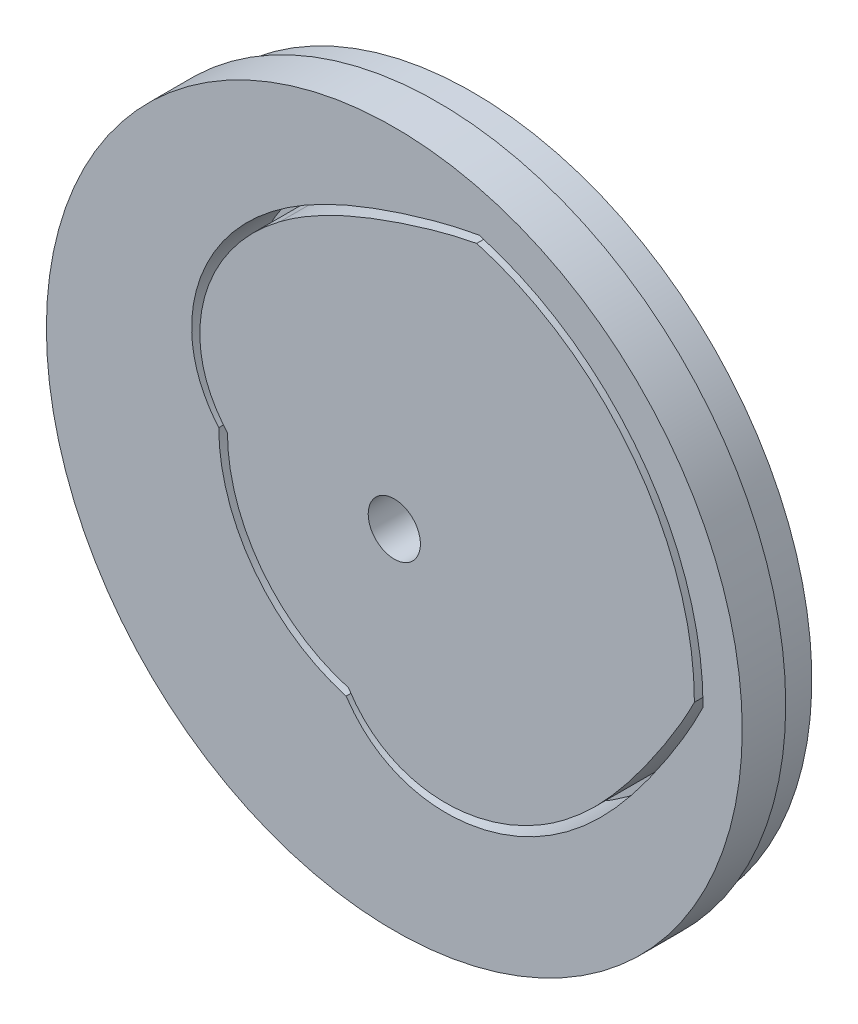
from build123d import *

# Parameters (mm, degrees)
SKETCH_1_R          = 36
EXTRUDE_1_DEPTH     = 2
SKETCH_2_R          = 30
EXTRUDE_2_DEPTH     = 5
SKETCH_3_R          = 3
CUT_EXTRUDE_1_DEPTH = 25
SKETCH_4_R          = 39
EXTRUDE_3_DEPTH     = 2
SKETCH_5_R          = 40
EXTRUDE_4_DEPTH     = 5
SKETCH_6_R          = 3
CUT_EXTRUDE_2_DEPTH = 10
SKETCH_7_R          = 39
EXTRUDE_5_DEPTH     = 2
CUT_EXTRUDE_3_DEPTH = 8
SKETCH_11_R         = 3
CUT_EXTRUDE_4_DEPTH = 10


with BuildPart() as part:
    # 草图1 → 凸台-拉伸1 (new body)
    with BuildSketch(Plane.XY):
        Circle(SKETCH_1_R)
    extrude(amount=EXTRUDE_1_DEPTH)

    # 草图2 → 凸台-拉伸2 (add)
    with BuildSketch(Plane.XY.offset(2)):
        Circle(SKETCH_2_R)
    extrude(amount=EXTRUDE_2_DEPTH)

    # 草图3 → 切除-拉伸1 (cut)
    with BuildSketch(Plane(origin=(0, 0, 0), x_dir=(-1, 0, 0), z_dir=(0, 0, -1))):
        Circle(SKETCH_3_R)
    extrude(amount=-CUT_EXTRUDE_1_DEPTH, mode=Mode.SUBTRACT)

    # 草图4 → 凸台-拉伸3 (add)
    with BuildSketch(Plane(origin=(0, 0, 0), x_dir=(-1, 0, 0), z_dir=(0, 0, -1))):
        Circle(SKETCH_4_R)
    extrude(amount=-EXTRUDE_3_DEPTH)

    # 草图5 → 凸台-拉伸4 (add)
    with BuildSketch(Plane.XY.offset(7)):
        Circle(SKETCH_5_R)
    extrude(amount=-EXTRUDE_4_DEPTH)

    # 草图6 → 切除-拉伸2 (cut)
    with BuildSketch(Plane(origin=(0, 0, 0), x_dir=(-1, 0, 0), z_dir=(0, 0, -1))):
        Circle(SKETCH_6_R)
    extrude(amount=-CUT_EXTRUDE_2_DEPTH, mode=Mode.SUBTRACT)

    # 草图7 → 凸台-拉伸5 (add)
    with BuildSketch(Plane(origin=(0, 0, 0), x_dir=(-1, 0, 0), z_dir=(0, 0, -1))):
        Circle(SKETCH_7_R)
    extrude(amount=EXTRUDE_5_DEPTH)

    # 草图9 → 切除-拉伸3 (cut, through all)
    with BuildSketch(Plane.XY):
        with BuildLine():
            ThreePointArc((9.750517331, 34.134695132), (28.340724808, 21.378805331), (35.5, 0))
            add(Edge.make_bspline(
                [(35.5, 0), (35.291831716, -0.433383755), (34.96980107, -1.074592529), (34.52418154, -1.915308269), (34.187218858, -2.531250794), (33.846850563, -3.136125059), (33.503977838, -3.730227641), (33.159288353, -4.31386212), (32.813411624, -4.887391808), (32.466780261, -5.45117135), (32.005816301, -6.186619882), (31.544345288, -6.90909253), (31.076364296, -7.615922545), (30.729539293, -8.135423458), (30.381597048, -8.647502186), (30.033478459, -9.152056858), (29.570761971, -9.811988074), (29.104673867, -10.460815875), (28.634649226, -11.098388551), (28.282371873, -11.567841648), (27.92861643, -12.030677745), (27.573187362, -12.487003446), (27.215827327, -12.936851733), (26.856351511, -13.380290873), (26.494533103, -13.81733315), (26.010016529, -14.38997063), (25.518692174, -14.9515568), (25.019993436, -15.501415577), (24.643682888, -15.90626894), (24.263999584, -16.304545875), (23.880813008, -16.696175021), (23.366072554, -17.208377634), (22.713223292, -17.831826042), (22.045042308, -18.434016116), (21.502579759, -18.901037327), (21.09236886, -19.243323179), (20.678094987, -19.578075579), (20.259732543, -19.905143208), (19.837292779, -20.22440024), (19.410768219, -20.535676054), (18.980204542, -20.838859753), (18.545542144, -21.133651278), (18.107023875, -21.420198703), (17.517720614, -21.790150941), (16.62329103, -22.318325608), (15.7067858, -22.80295008), (14.623171032, -23.322232407), (13.837904271, -23.660560667), (13.041508576, -23.964526743), (12.561991359, -24.135860585), (12.079951879, -24.296349082), (11.595562292, -24.445767316), (11.10901483, -24.583905748), (10.458457055, -24.752534599), (9.803605775, -24.898001802), (9.145603452, -25.019145994), (8.651622009, -25.097480876), (8.156913973, -25.163146926), (7.661759162, -25.215898805), (7.166458386, -25.255485986), (6.671327047, -25.281650862), (6.17669929, -25.294143558), (5.682922868, -25.292727141), (5.190368209, -25.2770878), (4.699415784, -25.247017461), (4.210489856, -25.202244466), (3.723954401, -25.142467722), (2.439986898, -24.943551988), (1.175279325, -24.597845247), (-0.021822821, -24.097714557), (-0.463649413, -23.893489908), (-0.897552628, -23.672528344), (-1.322955162, -23.434869075), (-1.739200354, -23.180599491), (-2.145616319, -22.909839492), (-2.541596739, -22.622881923), (-2.926463418, -22.320009878), (-3.299660517, -22.001730531), (-3.660561801, -21.66856071), (-4.008686645, -21.321253094), (-4.343545551, -20.960637151), (-4.664752517, -20.587727939), (-5.074146394, -20.076174898), (-5.360533295, -19.676978176), (-5.543215795, -19.405737645)],
                knots=[0, 0, 0, 0, 0.026563969, 0.039640384, 0.05257194, 0.065355143, 0.077988297, 0.090471413, 0.102805833, 0.114993314, 0.127037876, 0.150763336, 0.162357092, 0.173875575, 0.185275851, 0.196563707, 0.207744758, 0.229808392, 0.240701862, 0.251509872, 0.262237274, 0.272888592, 0.283468254, 0.293980283, 0.304428565, 0.314816728, 0.335425387, 0.345652335, 0.355831222, 0.365964562, 0.376054677, 0.386103708, 0.406085782, 0.425925221, 0.435795506, 0.445634417, 0.45544314, 0.465222771, 0.474974271, 0.484698547, 0.494396408, 0.50406868, 0.513715654, 0.523338337, 0.542511584, 0.571097127, 0.580582239, 0.608903234, 0.618301964, 0.627679451, 0.637035769, 0.64637102, 0.655685281, 0.664978638, 0.683501515, 0.692732564, 0.701943084, 0.711133234, 0.720303225, 0.729453327, 0.738583878, 0.747695263, 0.756787959, 0.765862682, 0.774920056, 0.78396098, 0.792986518, 0.801997762, 0.855760925, 0.864720518, 0.873681538, 0.882646657, 0.891618236, 0.90059859, 0.909589965, 0.918593788, 0.9276114, 0.936642769, 0.945687449, 0.954743092, 0.963806242, 0.972871393, 0.981930868, 1, 1, 1, 1], degree=3))
            ThreePointArc((-5.543215795, -19.405737645), (-16.111837769, -12.153953208), (-20.18192, 0))
            add(Edge.make_bspline(
                [(9.750517331, 34.134695132), (9.276625195, 34.053567102), (8.571627127, 33.920037506), (7.640849763, 33.72246924), (6.956044952, 33.567642194), (6.28094733, 33.406500476), (5.615519246, 33.23999207), (4.959657675, 33.068861581), (4.313186179, 32.893814101), (3.675882576, 32.715363011), (2.84210938, 32.474127501), (2.020673754, 32.228840452), (1.21249111, 31.972997348), (0.617710027, 31.782198387), (0.02975881, 31.588286558), (-0.551006154, 31.392138591), (-1.312647731, 31.128476182), (-2.064538979, 30.858522137), (-2.806689187, 30.58169159), (-3.354844814, 30.371903718), (-3.897043903, 30.15887716), (-4.433442662, 29.942453181), (-4.964143489, 29.722393397), (-5.489262786, 29.498538852), (-6.00887466, 29.27067483), (-6.692567422, 28.96207444), (-7.367503742, 28.643892711), (-8.033189161, 28.315399137), (-8.525830532, 28.064759248), (-9.013074768, 27.809070018), (-9.494889102, 27.54818635), (-10.128772645, 27.193925279), (-10.907556852, 26.737422011), (-11.670111355, 26.260337802), (-12.268165359, 25.867011173), (-12.709956674, 25.566589769), (-13.145620215, 25.260192494), (-13.575017513, 24.947753173), (-13.99802449, 24.629248065), (-14.414479141, 24.304623119), (-14.824262289, 23.973891796), (-15.227101784, 23.636914371), (-15.623073304, 23.293965025), (-16.140656924, 22.828937943), (-16.894184597, 22.113977241), (-17.611900337, 21.365828302), (-18.408839731, 20.466515952), (-18.949839426, 19.804376068), (-19.460855182, 19.122097258), (-19.757305025, 18.708080908), (-20.044019397, 18.28866049), (-20.320734747, 17.863939763), (-20.587196796, 17.434046014), (-20.928024099, 16.854824245), (-21.2477598, 16.265112462), (-21.544973409, 15.665690204), (-21.755973745, 15.21222259), (-21.954992052, 14.754576673), (-22.141715569, 14.292954126), (-22.315820785, 13.82757538), (-22.47697337, 13.358672951), (-22.624841283, 12.886499502), (-22.759101186, 12.411324335), (-22.879349598, 11.933417439), (-22.985281943, 11.453087504), (-23.076520484, 10.97066786), (-23.152675736, 10.486425786), (-23.314067834, 9.19720408), (-23.329024422, 7.886183601), (-23.176927425, 6.597754031), (-23.10191029, 6.116826932), (-23.008623676, 5.638921481), (-22.896946721, 5.164603548), (-22.766783093, 4.694528542), (-22.618063541, 4.229375439), (-22.450903113, 3.769807673), (-22.265387741, 3.316555114), (-22.061852425, 2.870291523), (-21.840622115, 2.431761004), (-21.60228853, 2.001632431), (-21.347514791, 1.580604299), (-21.0771709, 1.169326564), (-20.697736955, 0.635173269), (-20.392552787, 0.250156252), (-20.18192, 0)],
                knots=[0, 0, 0, 0, 0.026563969, 0.039640384, 0.05257194, 0.065355143, 0.077988297, 0.090471413, 0.102805833, 0.114993314, 0.127037876, 0.150763336, 0.162357092, 0.173875575, 0.185275851, 0.196563707, 0.207744758, 0.229808392, 0.240701862, 0.251509872, 0.262237274, 0.272888592, 0.283468254, 0.293980283, 0.304428565, 0.314816728, 0.335425387, 0.345652335, 0.355831222, 0.365964562, 0.376054677, 0.386103708, 0.406085782, 0.425925221, 0.435795506, 0.445634417, 0.45544314, 0.465222771, 0.474974271, 0.484698547, 0.494396408, 0.50406868, 0.513715654, 0.523338337, 0.542511584, 0.571097127, 0.580582239, 0.608903234, 0.618301964, 0.627679451, 0.637035769, 0.64637102, 0.655685281, 0.664978638, 0.683501515, 0.692732564, 0.701943084, 0.711133234, 0.720303225, 0.729453327, 0.738583878, 0.747695263, 0.756787959, 0.765862682, 0.774920056, 0.78396098, 0.792986518, 0.801997762, 0.855760925, 0.864720518, 0.873681538, 0.882646657, 0.891618236, 0.90059859, 0.909589965, 0.918593788, 0.9276114, 0.936642769, 0.945687449, 0.954743092, 0.963806242, 0.972871393, 0.981930868, 1, 1, 1, 1], degree=3))
        make_face()
        with BuildLine():
            ThreePointArc((34.500125587, 2.0246e-05), (27.542495364, 20.776660334), (9.475910662, 33.173269098))
            add(Edge.make_bspline(
                [(9.475910662, 33.173269098), (9.013913327, 33.088680351), (8.326808416, 32.950488792), (7.420043536, 32.747192756), (6.75331292, 32.588451315), (6.096358822, 32.423726512), (5.449135609, 32.253973709), (4.811539365, 32.07992431), (4.183369793, 31.902335747), (3.564459688, 31.72153339), (2.954440076, 31.53828841), (2.352525087, 31.351665668), (1.758990071, 31.165688291), (0.984309831, 30.911189088), (0.220337484, 30.655169), (-0.533246889, 30.392264086), (-1.270235467, 30.12935389), (-2.175420837, 29.794996076), (-3.067464519, 29.449341561), (-3.768708175, 29.167116193), (-4.286792713, 28.953230031), (-4.799229233, 28.736045918), (-5.473007881, 28.442776413), (-6.302109339, 28.066899275), (-7.11816844, 27.675355256), (-7.760089554, 27.353350014), (-8.547980485, 26.946168197), (-9.322302527, 26.521335434), (-10.081266264, 26.077572125), (-10.529258211, 25.807158533), (-10.971694032, 25.531414666), (-11.408457906, 25.250196969), (-11.839478469, 24.963462846), (-12.405461461, 24.574285655), (-12.822346782, 24.272983826), (-13.096470327, 24.067932955)],
                knots=[0, 0, 0, 0, 0.057468943, 0.085747572, 0.113703692, 0.141329188, 0.168619993, 0.195575901, 0.222199665, 0.248495134, 0.274471054, 0.300136345, 0.325604897, 0.350577138, 0.399909964, 0.424192528, 0.448235956, 0.495654563, 0.542261904, 0.565289675, 0.588147159, 0.610844297, 0.633390119, 0.678061544, 0.722224403, 0.7441329, 0.765934053, 0.830744152, 0.852168247, 0.873509251, 0.89477083, 0.915956589, 0.937069567, 0.958112714, 1, 1, 1, 1], degree=3))
            add(Edge.make_bspline(
                [(-13.096470327, 24.067932955), (-13.368963871, 23.864120075), (-13.77213365, 23.552158671), (-14.298173799, 23.1233423), (-14.685376955, 22.796234792), (-15.065898088, 22.463442741), (-15.439312594, 22.124672191), (-15.805582669, 21.780081052), (-16.164491187, 21.429648803), (-16.515860693, 21.073411924), (-16.859497479, 20.711403416), (-17.195198153, 20.343663263), (-17.522778751, 19.970261176), (-17.842001633, 19.59123373), (-18.15266064, 19.206659576), (-18.454537459, 18.816621075), (-18.747404901, 18.421205896), (-19.031014722, 18.020501892), (-19.305142161, 17.614621735), (-19.5695186, 17.203680977), (-19.82391187, 16.78776272), (-20.550400382, 15.5357346), (-21.160006232, 14.214541123), (-21.617168003, 12.847751758), (-21.755744211, 12.391540553), (-21.880999444, 11.932518869), (-21.99254555, 11.470921631), (-22.090079076, 11.007066815), (-22.17322017, 10.541250718), (-22.241603605, 10.073845838), (-22.294848845, 9.605063313), (-22.445544604, 7.740069827), (-22.239355508, 5.817714268), (-21.634875161, 4.04547041), (-21.464499432, 3.604036513), (-21.276078194, 3.169065137), (-21.069982947, 2.741109475), (-20.846531739, 2.320938845), (-20.606318622, 1.909206667), (-20.350007882, 1.506607746), (-20.078470939, 1.113784619), (-19.697869025, 0.60419586), (-19.392437234, 0.237795434), (-19.181864208, 0.000114673)],
                knots=[0, 0, 0, 0, 0.036454691, 0.054604205, 0.072704004, 0.090754654, 0.108758162, 0.126715261, 0.144626885, 0.162493865, 0.180316934, 0.198096729, 0.215833755, 0.233528582, 0.251181595, 0.268793115, 0.286363443, 0.303892874, 0.321381592, 0.338829843, 0.356237829, 0.373605776, 0.493926776, 0.510985841, 0.528009093, 0.54499761, 0.561952954, 0.578876512, 0.595770236, 0.612636413, 0.6294774, 0.646296276, 0.813191496, 0.830049983, 0.846939631, 0.86386334, 0.880821258, 0.897812697, 0.914833155, 0.931875915, 0.948930156, 0.965980721, 1, 1, 1, 1], degree=3))
            ThreePointArc((-19.181864208, 0.000114673), (-15.313463272, -11.551699319), (-5.268428766, -18.444174497))
            add(Edge.make_bspline(
                [(19.545187475, -19.203348101), (19.274369336, -19.409381974), (18.863670127, -19.71136202), (18.306862227, -20.099391247), (17.885984855, -20.381858668), (17.461476865, -20.656339721), (17.033172229, -20.922345393), (16.601233168, -21.179882706), (16.165699585, -21.428737249), (15.726655297, -21.668748411), (15.284185243, -21.899738998), (14.838383731, -22.121524422), (14.389368319, -22.333946942), (13.937239447, -22.536788102), (13.482129365, -22.729871275), (13.024177229, -22.913009166), (12.563529736, -23.086007402), (12.100339544, -23.248651417), (11.634776725, -23.40075604), (11.167026167, -23.542094723), (10.697231543, -23.672467051), (9.293816397, -24.027130129), (7.85599923, -24.250408639), (6.416210438, -24.314582483), (5.93948311, -24.32252503), (5.463712164, -24.316886984), (4.989230103, -24.297359647), (4.516426018, -24.263738572), (4.045689144, -24.215739897), (3.577477965, -24.153114753), (3.11210002, -24.075555232), (1.277442416, -23.708211539), (-0.514348265, -22.981953324), (-2.052404761, -21.913951921), (-2.43006559, -21.628883381), (-2.796556017, -21.328238362), (-3.151446163, -21.012526017), (-3.494083651, -20.682263467), (-3.824003356, -20.338201385), (-4.14071965, -19.981169347), (-4.443854053, -19.612181739), (-4.829307303, -19.106252582), (-5.097725559, -18.711931025), (-5.268428766, -18.444174497)],
                knots=[0, 0, 0, 0, 0.036454691, 0.054604205, 0.072704004, 0.090754654, 0.108758162, 0.126715261, 0.144626885, 0.162493865, 0.180316934, 0.198096729, 0.215833755, 0.233528582, 0.251181595, 0.268793115, 0.286363443, 0.303892874, 0.321381592, 0.338829843, 0.356237829, 0.373605776, 0.493926776, 0.510985841, 0.528009093, 0.54499761, 0.561952954, 0.578876512, 0.595770236, 0.612636413, 0.6294774, 0.646296276, 0.813191496, 0.830049983, 0.846939631, 0.86386334, 0.880821258, 0.897812697, 0.914833155, 0.931875915, 0.948930156, 0.965980721, 1, 1, 1, 1], degree=3))
            add(Edge.make_bspline(
                [(34.500125587, 2.0246e-05), (34.291896716, -0.420975634), (33.970297947, -1.043698926), (33.525766215, -1.859752456), (33.190003953, -2.457240751), (32.851173689, -3.043685121), (32.510181506, -3.619391846), (32.16770214, -4.184661736), (31.824408876, -4.73989542), (31.480568648, -5.285343041), (31.136821623, -5.821571195), (30.792052779, -6.34907868), (30.450206144, -6.868705736), (29.992719182, -7.54369092), (29.536710885, -8.207962299), (29.076935735, -8.860354215), (28.621713747, -9.496787148), (28.051594615, -10.275324157), (27.474222774, -11.038122121), (27.010246253, -11.634879703), (26.662287603, -12.074292557), (26.312709138, -12.507368789), (25.845656839, -13.074684238), (25.256512585, -13.768659669), (24.655886234, -14.445791238), (24.169953424, -14.974581742), (23.562027435, -15.620333352), (22.940856207, -16.24818987), (22.305700841, -16.856079243), (21.922640574, -17.212569253), (21.535981091, -17.562252795), (21.145616168, -17.904979074), (20.75152445, -18.240667769), (20.221860434, -18.677991062), (19.817643693, -18.996086946), (19.545187475, -19.203348101)],
                knots=[0, 0, 0, 0, 0.057468943, 0.085747572, 0.113703692, 0.141329188, 0.168619993, 0.195575901, 0.222199665, 0.248495134, 0.274471054, 0.300136345, 0.325604897, 0.350577138, 0.399909964, 0.424192528, 0.448235956, 0.495654563, 0.542261904, 0.565289675, 0.588147159, 0.610844297, 0.633390119, 0.678061544, 0.722224403, 0.7441329, 0.765934053, 0.830744152, 0.852168247, 0.873509251, 0.89477083, 0.915956589, 0.937069567, 0.958112714, 1, 1, 1, 1], degree=3))
        make_face(mode=Mode.SUBTRACT)
    extrude(amount=CUT_EXTRUDE_3_DEPTH, mode=Mode.SUBTRACT)

    # 草图11 → 切除-拉伸4 (cut)
    with BuildSketch(Plane.XY.offset(7)):
        Circle(SKETCH_11_R)
    extrude(amount=-CUT_EXTRUDE_4_DEPTH, mode=Mode.SUBTRACT)


solid = part.part
